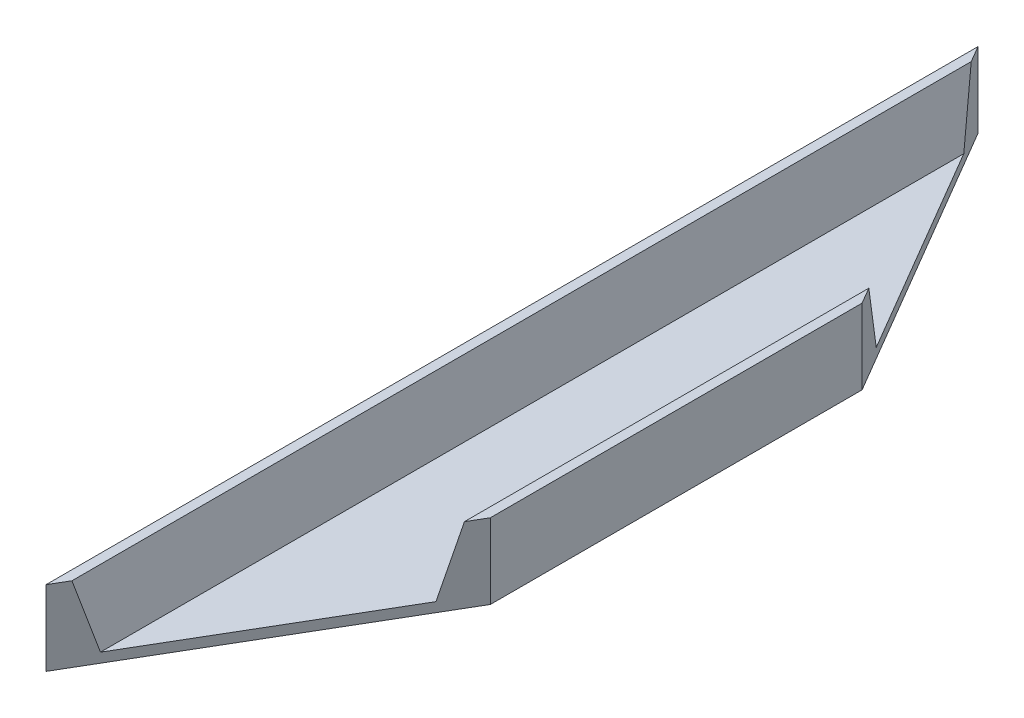
from build123d import *

# Parameters (mm, degrees)
BOSS_EXTRUDE1_DEPTH     = 432.4604
CUT_EXTRUDE1_DEPTH      = 18.43075
CUT_EXTRUDE1_DEPTH_BACK = 18.43075


with BuildPart() as part:
    # Sketch1 → Boss-Extrude1 (new body)
    with BuildSketch(Plane.XY):
        Polygon((-28.7655, -12.98575), (28.7655, -12.98575), (33.655, 17.43075), (38.1, 17.43075), (38.1, -17.43075), (-38.1, -17.43075), (-38.1, 17.43075), (-33.655, 17.43075), align=None)
    extrude(amount=BOSS_EXTRUDE1_DEPTH)

    # Sketch2 → Cut-Extrude1 (cut, two sides)
    with BuildSketch(Plane(origin=(0, 0, 0), x_dir=(1, 0, 0), z_dir=(0, 1, 0))) as cut_extrude1_sk:
        Polygon((-38.1, 0), (38.1, -129.9972), (38.1, 0), align=None)
        Polygon((-38.1, -432.4604), (38.1, -302.4632), (38.1, -432.4604), align=None)
    extrude(amount=CUT_EXTRUDE1_DEPTH, mode=Mode.SUBTRACT)
    extrude(cut_extrude1_sk.sketch, amount=-CUT_EXTRUDE1_DEPTH_BACK, mode=Mode.SUBTRACT)


solid = part.part
